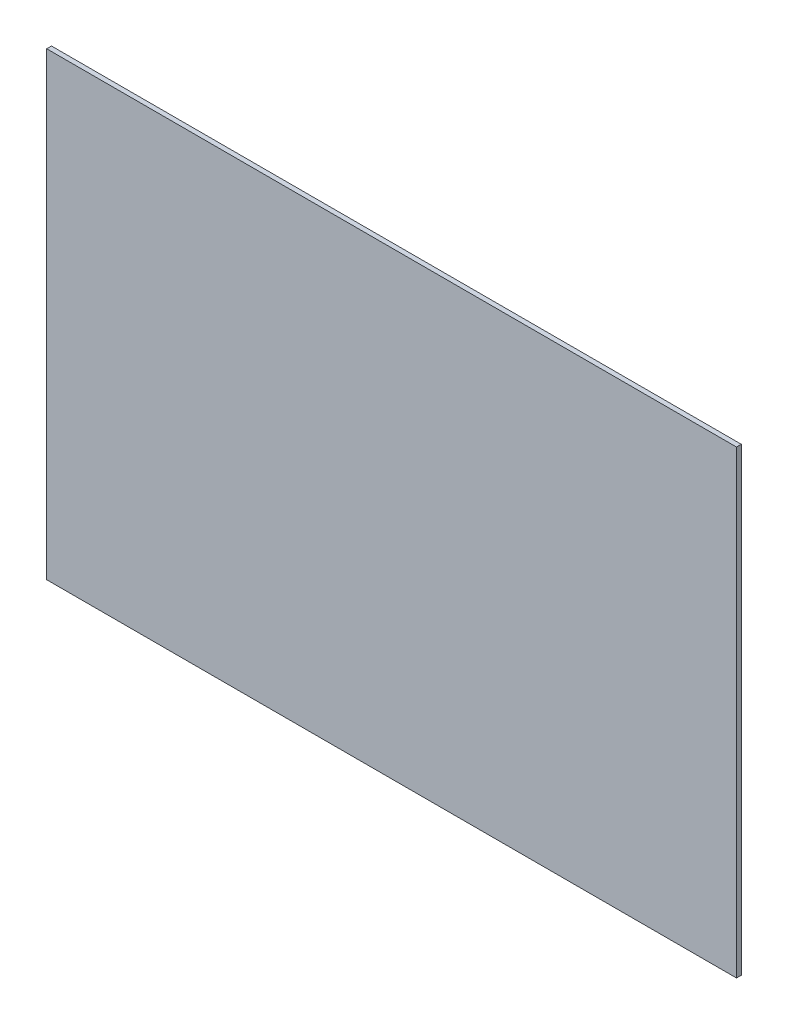
from build123d import *

# Parameters (mm, degrees)
SKETCH1_W           = 457.2
SKETCH1_H           = 304.8
BOSS_EXTRUDE1_DEPTH = 3.175


with BuildPart() as part:
    # Sketch1 → Boss-Extrude1 (new body)
    with BuildSketch(Plane.XY):
        with Locations((-28.887051482, 14.146333853)):
            Rectangle(SKETCH1_W, SKETCH1_H)
    extrude(amount=BOSS_EXTRUDE1_DEPTH)


solid = part.part
